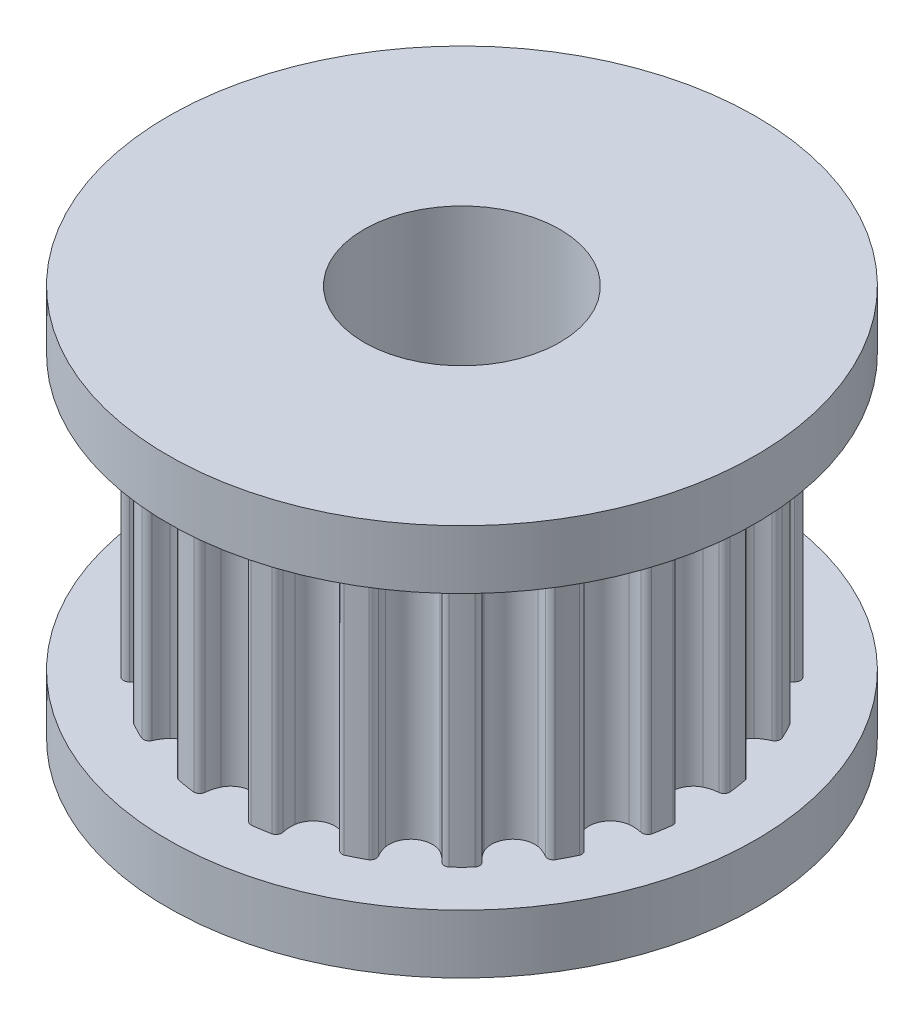
from build123d import *

# Parameters (mm, degrees)
SKETCH2_R           = 6.366203101
SKETCH2_R_2         = 4.366203101
CUT_EXTRUDE1_DEPTH  = 7
BOSS_EXTRUDE1_REACH = 10.5
SKETCH3_R           = 4.366203101


with BuildPart() as part:
    # Sketch1 → Revolve1 (revolve)
    with BuildSketch(Plane.XY):
        Polygon((2.5, 0), (2.5, 10), (7.5, 10), (7.5, 8.5), (6.366203101, 8.5), (6.366203101, 1.5), (7.5, 1.5), (7.5, 0), align=None)
    revolve(axis=Axis((0, 0, 0), (0, 1, 0)))

    # Sketch2 → Cut-Extrude1 (cut)
    with BuildSketch(Plane(origin=(0, 1.5, 0), x_dir=(1, 0, 0), z_dir=(0, 1, 0))):
        Circle(SKETCH2_R)
        Circle(SKETCH2_R_2, mode=Mode.SUBTRACT)
    extrude(amount=CUT_EXTRUDE1_DEPTH, mode=Mode.SUBTRACT)

    # Sketch3 → Boss-Extrude1 (add, up to next)
    with BuildSketch(Plane(origin=(0, 1.5, 0), x_dir=(1, 0, 0), z_dir=(0, 1, 0)), mode=Mode.PRIVATE) as boss_extrude1_sk1:
        with BuildLine():
            ThreePointArc((6.039931364, -1.194567246), (6.081158405, -0.96316087), (6.113457662, -0.730340473))
            ThreePointArc((6.113457662, -0.730340473), (6.076174412, -0.631371113), (5.98285854, -0.581600411))
            ThreePointArc((5.98285854, -0.581600411), (5.817334791, -0.552657178), (5.658994178, -0.496407091))
            ThreePointArc((5.658994178, -0.496407091), (5.435086525, -0.291780767), (5.352197724, 0))
            ThreePointArc((5.352197724, 0), (5.435086525, 0.291780767), (5.658994178, 0.496407091))
            ThreePointArc((5.658994178, 0.496407091), (5.817334791, 0.552657178), (5.98285854, 0.581600411))
            ThreePointArc((5.98285854, 0.581600411), (6.076174412, 0.631371113), (6.113457662, 0.730340473))
            ThreePointArc((6.113457662, 0.730340473), (6.081158405, 0.96316087), (6.039931364, 1.194567246))
            ThreePointArc((6.039931364, 1.194567246), (5.973889673, 1.277171543), (5.869761011, 1.295670103))
            ThreePointArc((5.869761011, 1.295670103), (5.703394621, 1.272047103), (5.535421516, 1.276614173))
            ThreePointArc((5.535421516, 1.276614173), (5.259239672, 1.402034102), (5.090242522, 1.653920054))
            ThreePointArc((5.090242522, 1.653920054), (5.078909241, 1.957034102), (5.228625062, 2.220836571))
            ThreePointArc((5.228625062, 2.220836571), (5.361833701, 2.323263522), (5.510312189, 2.401939825))
            ThreePointArc((5.510312189, 2.401939825), (5.583680865, 2.478110765), (5.588556129, 2.583757378))
            ThreePointArc((5.588556129, 2.583757378), (5.48589225, 2.795201715), (5.375174502, 3.0025424))
            ThreePointArc((5.375174502, 3.0025424), (5.286838989, 3.06069575), (5.182090378, 3.0461114))
            ThreePointArc((5.182090378, 3.0461114), (5.031166447, 2.972234549), (4.870003228, 2.924671548))
            ThreePointArc((4.870003228, 2.924671548), (4.568581797, 2.958608105), (4.330018916, 3.145942889))
            ThreePointArc((4.330018916, 3.145942889), (4.225572933, 3.430719304), (4.286441694, 3.727875093))
            ThreePointArc((4.286441694, 3.727875093), (4.38147897, 3.866452647), (4.498378089, 3.987160633))
            ThreePointArc((4.498378089, 3.987160633), (4.544617731, 4.08227567), (4.516607784, 4.184258108))
            ThreePointArc((4.516607784, 4.184258108), (4.35362874, 4.35362874), (4.184258108, 4.516607784))
            ThreePointArc((4.184258108, 4.516607784), (4.08227567, 4.544617731), (3.987160633, 4.498378089))
            ThreePointArc((3.987160633, 4.498378089), (3.866452647, 4.38147897), (3.727875093, 4.286441694))
            ThreePointArc((3.727875093, 4.286441694), (3.430719304, 4.225572933), (3.145942889, 4.330018916))
            ThreePointArc((3.145942889, 4.330018916), (2.958608105, 4.568581797), (2.924671548, 4.870003228))
            ThreePointArc((2.924671548, 4.870003228), (2.972234549, 5.031166447), (3.0461114, 5.182090378))
            ThreePointArc((3.0461114, 5.182090378), (3.06069575, 5.286838989), (3.0025424, 5.375174502))
            ThreePointArc((3.0025424, 5.375174502), (2.795201715, 5.48589225), (2.583757378, 5.588556129))
            ThreePointArc((2.583757378, 5.588556129), (2.478110765, 5.583680865), (2.401939825, 5.510312189))
            ThreePointArc((2.401939825, 5.510312189), (2.323263522, 5.361833701), (2.220836571, 5.228625062))
            ThreePointArc((2.220836571, 5.228625062), (1.957034102, 5.078909241), (1.653920054, 5.090242522))
            ThreePointArc((1.653920054, 5.090242522), (1.402034102, 5.259239672), (1.276614173, 5.535421516))
            ThreePointArc((1.276614173, 5.535421516), (1.272047103, 5.703394621), (1.295670103, 5.869761011))
            ThreePointArc((1.295670103, 5.869761011), (1.277171543, 5.973889673), (1.194567246, 6.039931364))
            ThreePointArc((1.194567246, 6.039931364), (0.96316087, 6.081158405), (0.730340473, 6.113457662))
            ThreePointArc((0.730340473, 6.113457662), (0.631371113, 6.076174412), (0.581600411, 5.98285854))
            ThreePointArc((0.581600411, 5.98285854), (0.552657178, 5.817334791), (0.496407091, 5.658994178))
            ThreePointArc((0.496407091, 5.658994178), (0.291780767, 5.435086525), (0, 5.352197724))
            ThreePointArc((0, 5.352197724), (-0.291780767, 5.435086525), (-0.496407091, 5.658994178))
            ThreePointArc((-0.496407091, 5.658994178), (-0.552657178, 5.817334791), (-0.581600411, 5.98285854))
            ThreePointArc((-0.581600411, 5.98285854), (-0.631371113, 6.076174412), (-0.730340473, 6.113457662))
            ThreePointArc((-0.730340473, 6.113457662), (-0.96316087, 6.081158405), (-1.194567246, 6.039931364))
            ThreePointArc((-1.194567246, 6.039931364), (-1.277171543, 5.973889673), (-1.295670103, 5.869761011))
            ThreePointArc((-1.295670103, 5.869761011), (-1.272047103, 5.703394621), (-1.276614173, 5.535421516))
            ThreePointArc((-1.276614173, 5.535421516), (-1.402034102, 5.259239672), (-1.653920054, 5.090242522))
            ThreePointArc((-1.653920054, 5.090242522), (-1.957034102, 5.078909241), (-2.220836571, 5.228625062))
            ThreePointArc((-2.220836571, 5.228625062), (-2.323263522, 5.361833701), (-2.401939825, 5.510312189))
            ThreePointArc((-2.401939825, 5.510312189), (-2.478110765, 5.583680865), (-2.583757378, 5.588556129))
            ThreePointArc((-2.583757378, 5.588556129), (-2.795201715, 5.48589225), (-3.0025424, 5.375174502))
            ThreePointArc((-3.0025424, 5.375174502), (-3.06069575, 5.286838989), (-3.0461114, 5.182090378))
            ThreePointArc((-3.0461114, 5.182090378), (-2.972234549, 5.031166447), (-2.924671548, 4.870003228))
            ThreePointArc((-2.924671548, 4.870003228), (-2.958608105, 4.568581797), (-3.145942889, 4.330018916))
            ThreePointArc((-3.145942889, 4.330018916), (-3.430719304, 4.225572933), (-3.727875093, 4.286441694))
            ThreePointArc((-3.727875093, 4.286441694), (-3.866452647, 4.38147897), (-3.987160633, 4.498378089))
            ThreePointArc((-3.987160633, 4.498378089), (-4.08227567, 4.544617731), (-4.184258108, 4.516607784))
            ThreePointArc((-4.184258108, 4.516607784), (-4.35362874, 4.35362874), (-4.516607784, 4.184258108))
            ThreePointArc((-4.516607784, 4.184258108), (-4.544617731, 4.08227567), (-4.498378089, 3.987160633))
            ThreePointArc((-4.498378089, 3.987160633), (-4.38147897, 3.866452647), (-4.286441694, 3.727875093))
            ThreePointArc((-4.286441694, 3.727875093), (-4.225572933, 3.430719304), (-4.330018916, 3.145942889))
            ThreePointArc((-4.330018916, 3.145942889), (-4.568581797, 2.958608105), (-4.870003228, 2.924671548))
            ThreePointArc((-4.870003228, 2.924671548), (-5.031166447, 2.972234549), (-5.182090378, 3.0461114))
            ThreePointArc((-5.182090378, 3.0461114), (-5.286838989, 3.06069575), (-5.375174502, 3.0025424))
            ThreePointArc((-5.375174502, 3.0025424), (-5.48589225, 2.795201715), (-5.588556129, 2.583757378))
            ThreePointArc((-5.588556129, 2.583757378), (-5.583680865, 2.478110765), (-5.510312189, 2.401939825))
            ThreePointArc((-5.510312189, 2.401939825), (-5.361833701, 2.323263522), (-5.228625062, 2.220836571))
            ThreePointArc((-5.228625062, 2.220836571), (-5.078909241, 1.957034102), (-5.090242522, 1.653920054))
            ThreePointArc((-5.090242522, 1.653920054), (-5.259239672, 1.402034102), (-5.535421516, 1.276614173))
            ThreePointArc((-5.535421516, 1.276614173), (-5.703394621, 1.272047103), (-5.869761011, 1.295670103))
            ThreePointArc((-5.869761011, 1.295670103), (-5.973889673, 1.277171543), (-6.039931364, 1.194567246))
            ThreePointArc((-6.039931364, 1.194567246), (-6.081158405, 0.96316087), (-6.113457662, 0.730340473))
            ThreePointArc((-6.113457662, 0.730340473), (-6.076174412, 0.631371113), (-5.98285854, 0.581600411))
            ThreePointArc((-5.98285854, 0.581600411), (-5.817334791, 0.552657178), (-5.658994178, 0.496407091))
            ThreePointArc((-5.658994178, 0.496407091), (-5.435086525, 0.291780767), (-5.352197724, 0))
            ThreePointArc((-5.352197724, 0), (-5.435086525, -0.291780767), (-5.658994178, -0.496407091))
            ThreePointArc((-5.658994178, -0.496407091), (-5.817334791, -0.552657178), (-5.98285854, -0.581600411))
            ThreePointArc((-5.98285854, -0.581600411), (-6.076174412, -0.631371113), (-6.113457662, -0.730340473))
            ThreePointArc((-6.113457662, -0.730340473), (-6.081158405, -0.96316087), (-6.039931364, -1.194567246))
            ThreePointArc((-6.039931364, -1.194567246), (-5.973889673, -1.277171543), (-5.869761011, -1.295670103))
            ThreePointArc((-5.869761011, -1.295670103), (-5.703394621, -1.272047103), (-5.535421516, -1.276614173))
            ThreePointArc((-5.535421516, -1.276614173), (-5.259239672, -1.402034102), (-5.090242522, -1.653920054))
            ThreePointArc((-5.090242522, -1.653920054), (-5.078909241, -1.957034102), (-5.228625062, -2.220836571))
            ThreePointArc((-5.228625062, -2.220836571), (-5.361833701, -2.323263522), (-5.510312189, -2.401939825))
            ThreePointArc((-5.510312189, -2.401939825), (-5.583680865, -2.478110765), (-5.588556129, -2.583757378))
            ThreePointArc((-5.588556129, -2.583757378), (-5.48589225, -2.795201715), (-5.375174502, -3.0025424))
            ThreePointArc((-5.375174502, -3.0025424), (-5.286838989, -3.06069575), (-5.182090378, -3.0461114))
            ThreePointArc((-5.182090378, -3.0461114), (-5.031166447, -2.972234549), (-4.870003228, -2.924671548))
            ThreePointArc((-4.870003228, -2.924671548), (-4.568581797, -2.958608105), (-4.330018916, -3.145942889))
            ThreePointArc((-4.330018916, -3.145942889), (-4.225572933, -3.430719304), (-4.286441694, -3.727875093))
            ThreePointArc((-4.286441694, -3.727875093), (-4.38147897, -3.866452647), (-4.498378089, -3.987160633))
            ThreePointArc((-4.498378089, -3.987160633), (-4.544617731, -4.08227567), (-4.516607784, -4.184258108))
            ThreePointArc((-4.516607784, -4.184258108), (-4.35362874, -4.35362874), (-4.184258108, -4.516607784))
            ThreePointArc((-4.184258108, -4.516607784), (-4.08227567, -4.544617731), (-3.987160633, -4.498378089))
            ThreePointArc((-3.987160633, -4.498378089), (-3.866452647, -4.38147897), (-3.727875093, -4.286441694))
            ThreePointArc((-3.727875093, -4.286441694), (-3.430719304, -4.225572933), (-3.145942889, -4.330018916))
            ThreePointArc((-3.145942889, -4.330018916), (-2.958608105, -4.568581797), (-2.924671548, -4.870003228))
            ThreePointArc((-2.924671548, -4.870003228), (-2.972234549, -5.031166447), (-3.0461114, -5.182090378))
            ThreePointArc((-3.0461114, -5.182090378), (-3.06069575, -5.286838989), (-3.0025424, -5.375174502))
            ThreePointArc((-3.0025424, -5.375174502), (-2.795201715, -5.48589225), (-2.583757378, -5.588556129))
            ThreePointArc((-2.583757378, -5.588556129), (-2.478110765, -5.583680865), (-2.401939825, -5.510312189))
            ThreePointArc((-2.401939825, -5.510312189), (-2.323263522, -5.361833701), (-2.220836571, -5.228625062))
            ThreePointArc((-2.220836571, -5.228625062), (-1.957034102, -5.078909241), (-1.653920054, -5.090242522))
            ThreePointArc((-1.653920054, -5.090242522), (-1.402034102, -5.259239672), (-1.276614173, -5.535421516))
            ThreePointArc((-1.276614173, -5.535421516), (-1.272047103, -5.703394621), (-1.295670103, -5.869761011))
            ThreePointArc((-1.295670103, -5.869761011), (-1.277171543, -5.973889673), (-1.194567246, -6.039931364))
            ThreePointArc((-1.194567246, -6.039931364), (-0.96316087, -6.081158405), (-0.730340473, -6.113457662))
            ThreePointArc((-0.730340473, -6.113457662), (-0.631371113, -6.076174412), (-0.581600411, -5.98285854))
            ThreePointArc((-0.581600411, -5.98285854), (-0.552657178, -5.817334791), (-0.496407091, -5.658994178))
            ThreePointArc((-0.496407091, -5.658994178), (-0.291780767, -5.435086525), (0, -5.352197724))
            ThreePointArc((0, -5.352197724), (0.291780767, -5.435086525), (0.496407091, -5.658994178))
            ThreePointArc((0.496407091, -5.658994178), (0.552657178, -5.817334791), (0.581600411, -5.98285854))
            ThreePointArc((0.581600411, -5.98285854), (0.631371113, -6.076174412), (0.730340473, -6.113457662))
            ThreePointArc((0.730340473, -6.113457662), (0.96316087, -6.081158405), (1.194567246, -6.039931364))
            ThreePointArc((1.194567246, -6.039931364), (1.277171543, -5.973889673), (1.295670103, -5.869761011))
            ThreePointArc((1.295670103, -5.869761011), (1.272047103, -5.703394621), (1.276614173, -5.535421516))
            ThreePointArc((1.276614173, -5.535421516), (1.402034102, -5.259239672), (1.653920054, -5.090242522))
            ThreePointArc((1.653920054, -5.090242522), (1.957034102, -5.078909241), (2.220836571, -5.228625062))
            ThreePointArc((2.220836571, -5.228625062), (2.323263522, -5.361833701), (2.401939825, -5.510312189))
            ThreePointArc((2.401939825, -5.510312189), (2.478110765, -5.583680865), (2.583757378, -5.588556129))
            ThreePointArc((2.583757378, -5.588556129), (2.795201715, -5.48589225), (3.0025424, -5.375174502))
            ThreePointArc((3.0025424, -5.375174502), (3.06069575, -5.286838989), (3.0461114, -5.182090378))
            ThreePointArc((3.0461114, -5.182090378), (2.972234549, -5.031166447), (2.924671548, -4.870003228))
            ThreePointArc((2.924671548, -4.870003228), (2.958608105, -4.568581797), (3.145942889, -4.330018916))
            ThreePointArc((3.145942889, -4.330018916), (3.430719304, -4.225572933), (3.727875093, -4.286441694))
            ThreePointArc((3.727875093, -4.286441694), (3.866452647, -4.38147897), (3.987160633, -4.498378089))
            ThreePointArc((3.987160633, -4.498378089), (4.08227567, -4.544617731), (4.184258108, -4.516607784))
            ThreePointArc((4.184258108, -4.516607784), (4.35362874, -4.35362874), (4.516607784, -4.184258108))
            ThreePointArc((4.516607784, -4.184258108), (4.544617731, -4.08227567), (4.498378089, -3.987160633))
            ThreePointArc((4.498378089, -3.987160633), (4.38147897, -3.866452647), (4.286441694, -3.727875093))
            ThreePointArc((4.286441694, -3.727875093), (4.225572933, -3.430719304), (4.330018916, -3.145942889))
            ThreePointArc((4.330018916, -3.145942889), (4.568581797, -2.958608105), (4.870003228, -2.924671548))
            ThreePointArc((4.870003228, -2.924671548), (5.031166447, -2.972234549), (5.182090378, -3.0461114))
            ThreePointArc((5.182090378, -3.0461114), (5.286838989, -3.06069575), (5.375174502, -3.0025424))
            ThreePointArc((5.375174502, -3.0025424), (5.48589225, -2.795201715), (5.588556129, -2.583757378))
            ThreePointArc((5.588556129, -2.583757378), (5.583680865, -2.478110765), (5.510312189, -2.401939825))
            ThreePointArc((5.510312189, -2.401939825), (5.361833701, -2.323263522), (5.228625062, -2.220836571))
            ThreePointArc((5.228625062, -2.220836571), (5.078909241, -1.957034102), (5.090242522, -1.653920054))
            ThreePointArc((5.090242522, -1.653920054), (5.259239672, -1.402034102), (5.535421516, -1.276614173))
            ThreePointArc((5.535421516, -1.276614173), (5.703394621, -1.272047103), (5.869761011, -1.295670103))
            ThreePointArc((5.869761011, -1.295670103), (5.973889673, -1.277171543), (6.039931364, -1.194567246))
        make_face()
        Circle(SKETCH3_R, mode=Mode.SUBTRACT)
    boss_extrude1_tool1 = extrude(boss_extrude1_sk1.sketch, amount=BOSS_EXTRUDE1_REACH, mode=Mode.PRIVATE) - part.part
    add(boss_extrude1_tool1.solids().sort_by_distance((0.936111, 1.5, 5.910373))[0])


solid = part.part
